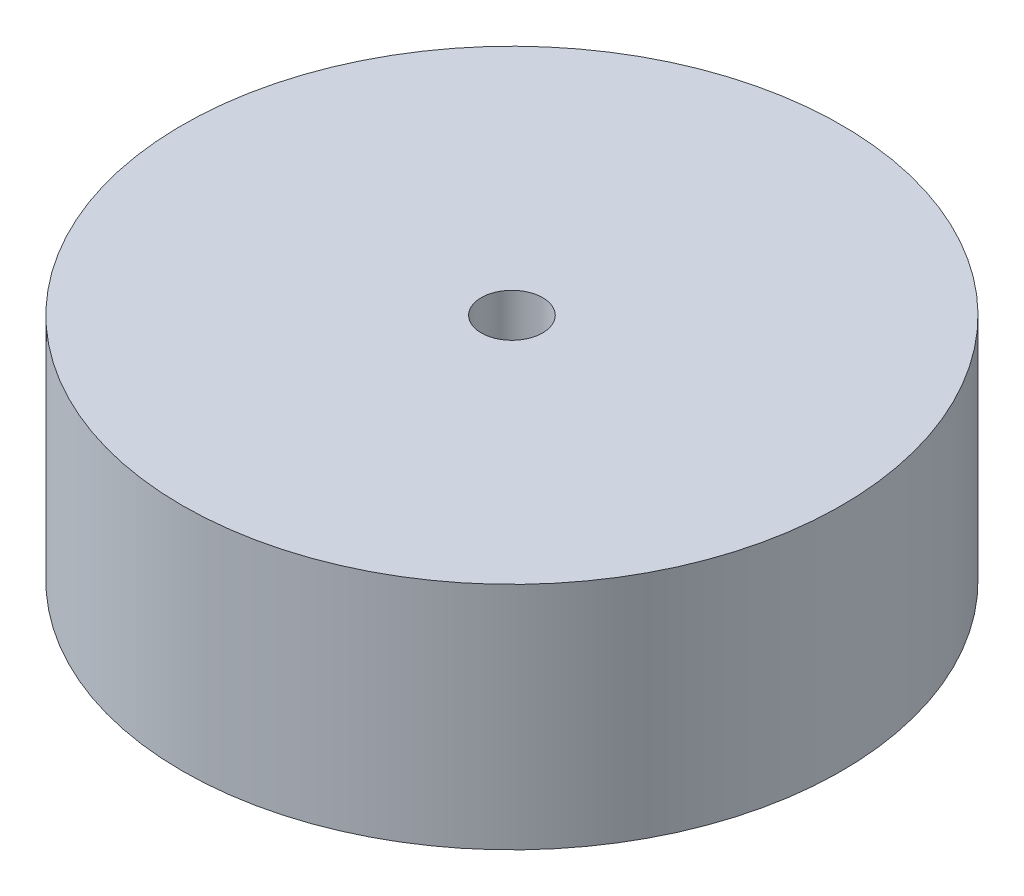
from build123d import *

# Parameters (mm, degrees)
SKETCH1_R               = 21.5
BOSS_EXTRUDE1_DEPTH     = 15
SKETCH2_R               = 2
CUT_EXTRUDE1_DEPTH      = 26
CUT_EXTRUDE1_DEPTH_BACK = 9


with BuildPart() as part:
    # Sketch1 → Boss-Extrude1 (new body)
    with BuildSketch(Plane(origin=(0, 0, 0), x_dir=(1, 0, 0), z_dir=(0, 1, 0))):
        Circle(SKETCH1_R)
    extrude(amount=BOSS_EXTRUDE1_DEPTH)

    # Sketch2 → Cut-Extrude1 (cut, two sides)
    with BuildSketch(Plane(origin=(0, 0, 0), x_dir=(1, 0, 0), z_dir=(0, 1, 0))) as cut_extrude1_sk:
        Circle(SKETCH2_R)
    extrude(amount=CUT_EXTRUDE1_DEPTH, mode=Mode.SUBTRACT)
    extrude(cut_extrude1_sk.sketch, amount=-CUT_EXTRUDE1_DEPTH_BACK, mode=Mode.SUBTRACT)


solid = part.part
